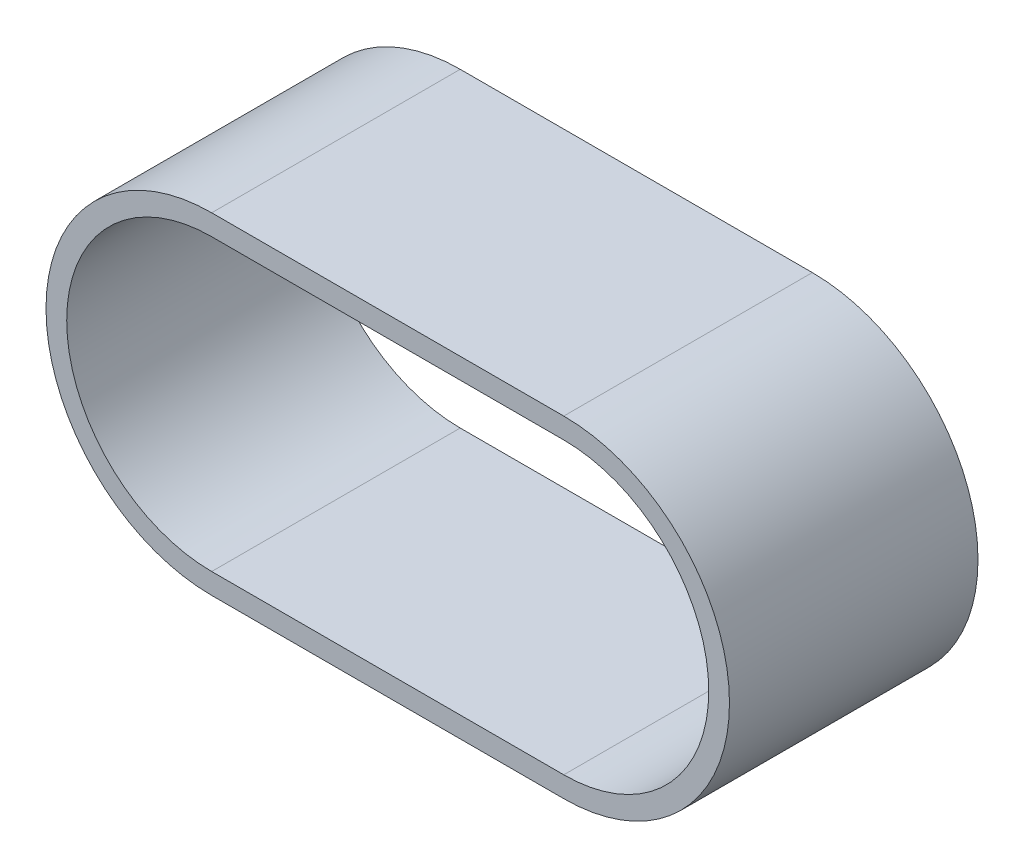
from build123d import *

# Parameters (mm, degrees)
BOSS_EXTRU_1_DEPTH = 60


with BuildPart() as part:
    # Esquisse1 → Boss.-Extru.1 (new body)
    with BuildSketch(Plane.XY):
        with BuildLine():
            Line((0, 40), (85, 40))
            ThreePointArc((85, 40), (125, 0), (85, -40))
            Line((85, -40), (0, -40))
            ThreePointArc((0, -40), (-40, 0), (0, 40))
        make_face()
        with BuildLine():
            Line((0, 35), (85, 35))
            ThreePointArc((85, 35), (120, 0), (85, -35))
            Line((85, -35), (0, -35))
            ThreePointArc((0, -35), (-35, 0), (0, 35))
        make_face(mode=Mode.SUBTRACT)
    extrude(amount=BOSS_EXTRU_1_DEPTH)


solid = part.part
